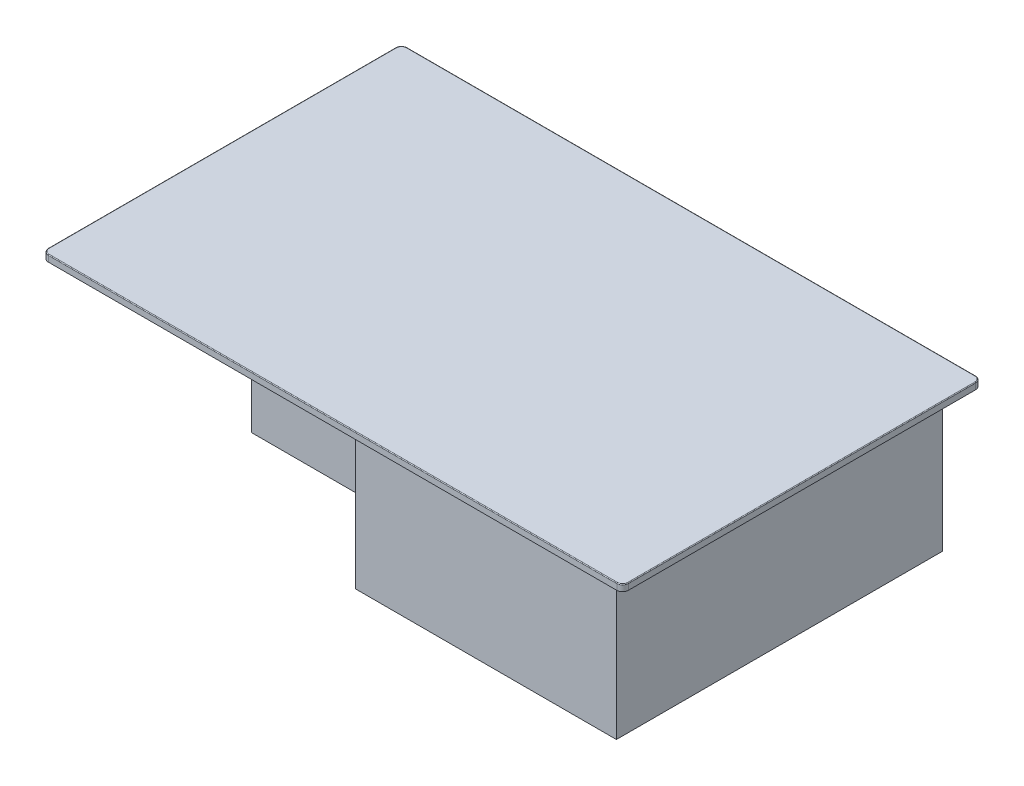
from build123d import *

# Parameters (mm, degrees)
SKETCH1_W           = 800
SKETCH1_H           = 495
BOSS_EXTRUDE1_DEPTH = 9
FILLET1_R           = 8
FILLET2_R           = 1
SKETCH2_W           = 775
SKETCH2_H           = 472
BOSS_EXTRUDE2_DEPTH = 4
SKETCH3_W           = 170
SKETCH3_H           = 380
BOSS_EXTRUDE3_DEPTH = 130
SKETCH4_W           = 360
SKETCH4_H           = 450
BOSS_EXTRUDE4_DEPTH = 210


with BuildPart() as part:
    # Sketch1 → Boss-Extrude1 (new body)
    with BuildSketch(Plane(origin=(0, 0, 0), x_dir=(1, 0, 0), z_dir=(0, 1, 0))):
        Rectangle(SKETCH1_W, SKETCH1_H)
    extrude(amount=-BOSS_EXTRUDE1_DEPTH)

    # Fillet1
    fillet1_edges = [part.edges().sort_by_distance(p)[0] for p in [
        (-400, -4.5, -247.5),
        (400, -4.5, -247.5),
        (400, -4.5, 247.5),
        (-400, -4.5, 247.5),
    ]]
    fillet(fillet1_edges, radius=FILLET1_R)

    # Fillet2
    fillet2_edges = [part.edges().sort_by_distance(p)[0] for p in [
        (400, 0, 0),
        (-400, 0, 0),
        (0, 0, 247.5),
        (0, 0, -247.5),
        (397.656854249, 0, 245.156854249),
        (-397.656854249, 0, 245.156854249),
        (-397.656854249, 0, -245.156854249),
        (397.656854249, 0, -245.156854249),
    ]]
    fillet(fillet2_edges, radius=FILLET2_R)

    # Sketch2 → Boss-Extrude2 (add)
    with BuildSketch(Plane.XZ.offset(9)):
        Rectangle(SKETCH2_W, SKETCH2_H)
    extrude(amount=BOSS_EXTRUDE2_DEPTH)

    # Sketch3 → Boss-Extrude3 (add)
    with BuildSketch(Plane(origin=(0, 0, 0), x_dir=(1, 0, 0), z_dir=(0, 1, 0))):
        with Locations((-84, 0)):
            Rectangle(SKETCH3_W, SKETCH3_H)
    extrude(amount=-BOSS_EXTRUDE3_DEPTH)

    # Sketch4 → Boss-Extrude4 (add)
    with BuildSketch(Plane(origin=(0, 0, 0), x_dir=(1, 0, 0), z_dir=(0, 1, 0))):
        with Locations((189, 0)):
            Rectangle(SKETCH4_W, SKETCH4_H)
    extrude(amount=-BOSS_EXTRUDE4_DEPTH)


solid = part.part
